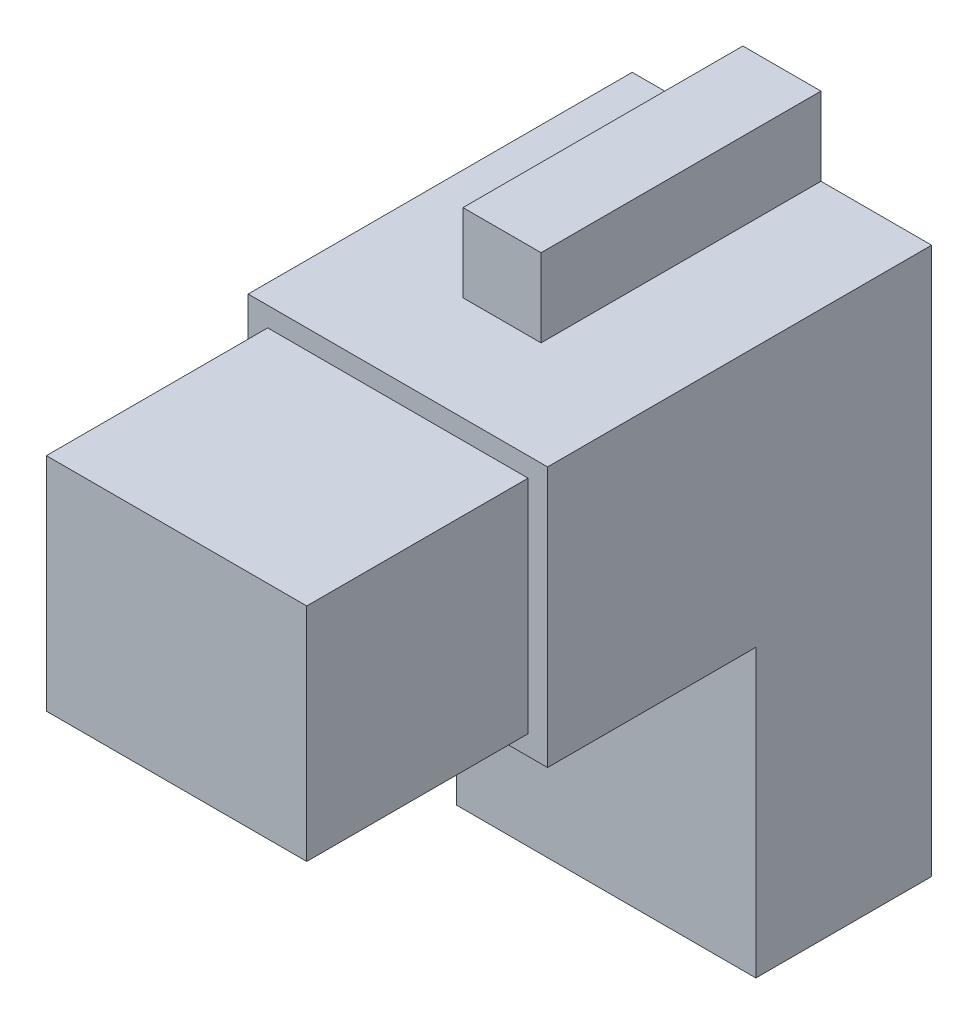
from build123d import *

# Parameters (mm, degrees)
SALIENTE_EXTRUIR1_DEPTH = 13.5
CROQUIS2_R              = 2
SALIENTE_EXTRUIR2_DEPTH = 1
CROQUIS6_W              = 6
CROQUIS6_H              = 6
SALIENTE_EXTRUIR3_DEPTH = 8
CROQUIS7_W              = 6
CROQUIS7_H              = 6
SALIENTE_EXTRUIR4_DEPTH = 8
CROQUIS8_W              = 23
CROQUIS8_H              = 20
SALIENTE_EXTRUIR5_DEPTH = 16
CROQUIS9_W              = 20
CROQUIS9_H              = 17
SALIENTE_EXTRUIR6_DEPTH = 17


with BuildPart() as part:
    # Croquis1 → Saliente-Extruir1 (new body)
    with BuildSketch(Plane.XY):
        Polygon((-9.958809275, -27.124651578), (13.041190725, -27.124651578), (13.041190725, 14.875348422), (4.541190725, 14.875348422), (4.541190725, 20.875348422), (-1.458809275, 20.875348422), (-1.458809275, 14.875348422), (-9.958809275, 14.875348422), align=None)
    extrude(amount=SALIENTE_EXTRUIR1_DEPTH)

    # Croquis2 → Saliente-Extruir2 (add)
    with BuildSketch(Plane(origin=(0, 0, 0), x_dir=(-1, 0, 0), z_dir=(0, 0, -1))):
        with Locations((-1.541190725, -16.124651578)):
            Circle(CROQUIS2_R)
    extrude(amount=SALIENTE_EXTRUIR2_DEPTH)

    # Croquis6 → Saliente-Extruir3 (add)
    with BuildSketch(Plane.XY.offset(13.5)):
        with Locations((1.541190725, -8.124651578)):
            Rectangle(CROQUIS6_W, CROQUIS6_H)
    extrude(amount=SALIENTE_EXTRUIR3_DEPTH)

    # Croquis7 → Saliente-Extruir4 (add)
    with BuildSketch(Plane.XY.offset(13.5)):
        with Locations((1.541190725, 17.875348422)):
            Rectangle(CROQUIS7_W, CROQUIS7_H)
    extrude(amount=SALIENTE_EXTRUIR4_DEPTH)

    # Croquis8 → Saliente-Extruir5 (add)
    with BuildSketch(Plane.XY.offset(13.5)):
        with Locations((1.541190725, 4.875348422)):
            Rectangle(CROQUIS8_W, CROQUIS8_H)
    extrude(amount=SALIENTE_EXTRUIR5_DEPTH)

    # Croquis9 → Saliente-Extruir6 (add)
    with BuildSketch(Plane.XY.offset(29.5)):
        with Locations((1.541190725, 4.875348422)):
            Rectangle(CROQUIS9_W, CROQUIS9_H)
    extrude(amount=SALIENTE_EXTRUIR6_DEPTH)


solid = part.part
